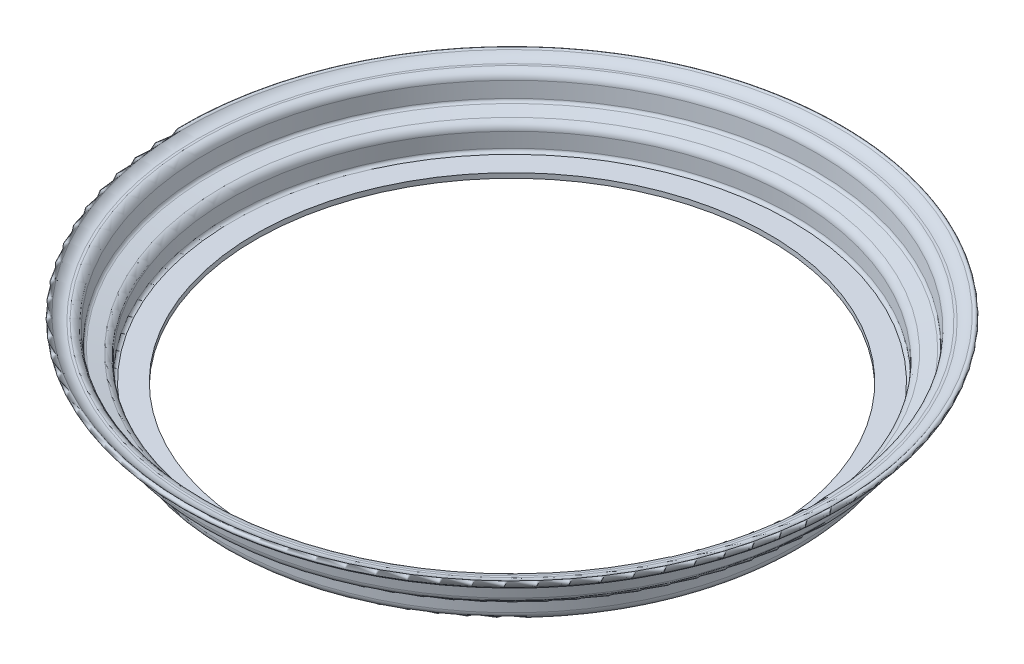
from build123d import *


with BuildPart() as part:
    # Sketch3 → Revolve2 (revolve)
    with BuildSketch(Plane.XY):
        with BuildLine():
            Line((-202.86479408, 33.056311154), (-202.015969434, 23.354201055))
            ThreePointArc((-202.015969434, 23.354201055), (-200.764119737, 20.406181688), (-198.018085623, 18.757775643))
            Line((-198.018085623, 18.757775643), (-189.605094554, 16.820471861))
            ThreePointArc((-189.605094554, 16.820471861), (-188.489033686, 16.116948575), (-188.053899467, 14.871478749))
            Line((-188.053899467, 14.871478749), (-188.053899467, 5.18))
            ThreePointArc((-188.053899467, 5.18), (-186.536712594, 1.517186873), (-182.873899467, 0))
            Line((-182.873899467, 0), (-168.157575681, 0))
            Line((-168.157575681, 0), (-168.157575681, 3.175))
            Line((-168.157575681, 3.175), (-182.878899467, 3.175))
            ThreePointArc((-182.878899467, 3.175), (-184.293113029, 3.760786438), (-184.878899467, 5.175))
            Line((-184.878899467, 5.175), (-184.878899467, 14.867499271))
            ThreePointArc((-184.878899467, 14.867499271), (-186.005897094, 18.09326612), (-188.896494742, 19.915391431))
            Line((-188.896494742, 19.915391431), (-197.309149985, 21.85261788))
            ThreePointArc((-197.309149985, 21.85261788), (-198.369394817, 22.489068091), (-198.852734468, 23.627299506))
            Line((-198.852734468, 23.627299506), (-199.701875913, 33.333030637))
            ThreePointArc((-199.701875913, 33.333030637), (-201.361004152, 36.697409886), (-204.857183476, 38.056999668))
            Line((-204.857183476, 38.056999668), (-206.357183499, 38.056999668))
            ThreePointArc((-206.357183499, 38.056999668), (-210.16007843, 38.862291983), (-213.310139829, 41.139926446))
            ThreePointArc((-213.310139829, 41.139926446), (-215.512219763, 41.2485817), (-215.620875017, 39.046501766))
            ThreePointArc((-215.620875017, 39.046501766), (-211.431068422, 35.980960403), (-206.357183476, 34.881999668))
            Line((-206.357183476, 34.881999668), (-204.857183476, 34.881999668))
            ThreePointArc((-204.857183476, 34.881999668), (-203.506003061, 34.356554342), (-202.86479408, 33.056311154))
        make_face()
    revolve(axis=Axis((0, 240.888952165, 0), (0, -1, 0)))


solid = part.part
